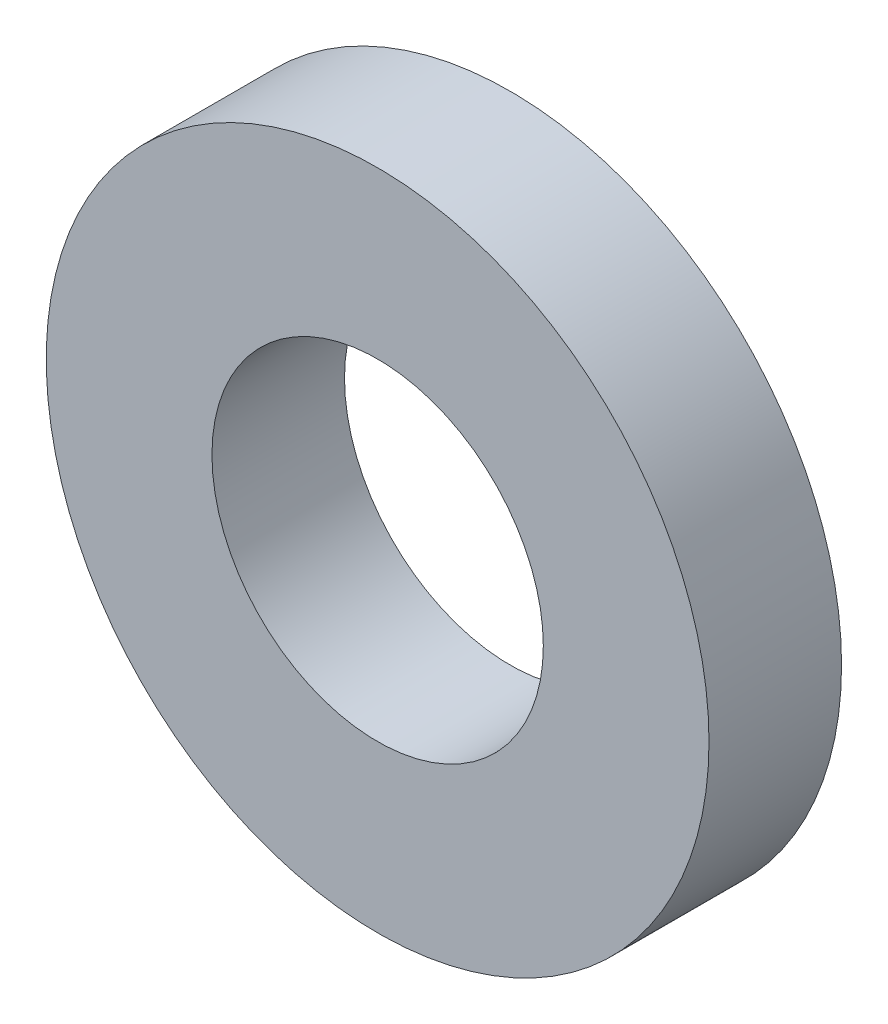
from build123d import *

# Parameters (mm, degrees)
SKETCH1_R           = 10
BOSS_EXTRUDE1_DEPTH = 4
SKETCH2_R           = 5
CUT_EXTRUDE1_DEPTH  = 4


with BuildPart() as part:
    # Sketch1 → Boss-Extrude1 (new body)
    with BuildSketch(Plane.XY):
        Circle(SKETCH1_R)
    extrude(amount=BOSS_EXTRUDE1_DEPTH)

    # Sketch2 → Cut-Extrude1 (cut)
    with BuildSketch(Plane.XY.offset(4)):
        Circle(SKETCH2_R)
    extrude(amount=-CUT_EXTRUDE1_DEPTH, mode=Mode.SUBTRACT)


solid = part.part
